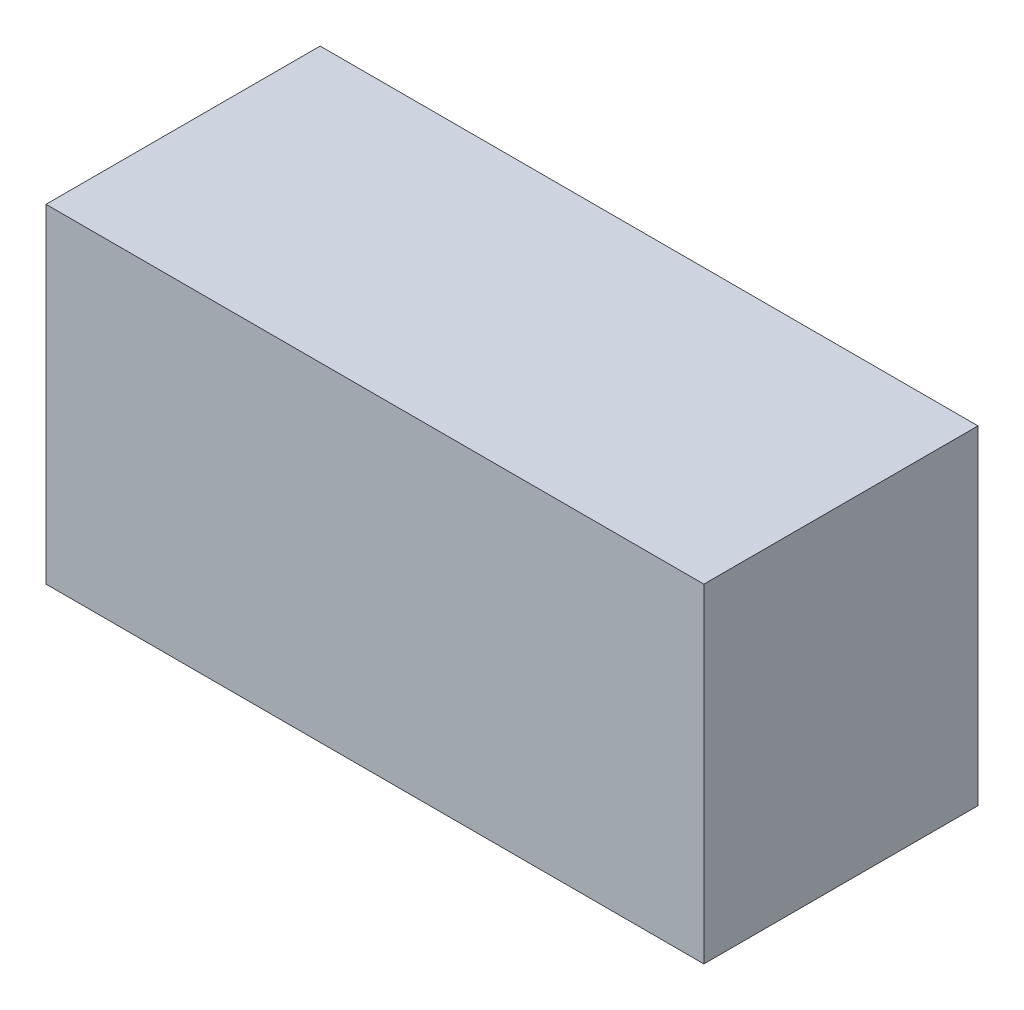
from build123d import *

# Parameters (mm, degrees)
SKETCH1_W           = 125
SKETCH1_H           = 150
BOSS_EXTRUDE1_DEPTH = 300


with BuildPart() as part:
    # Sketch1 → Boss-Extrude1 (new body)
    with BuildSketch(Plane(origin=(0, 0, 0), x_dir=(0, 0, -1), z_dir=(1, 0, 0))):
        with Locations((62.5, 75)):
            Rectangle(SKETCH1_W, SKETCH1_H)
    extrude(amount=BOSS_EXTRUDE1_DEPTH)


solid = part.part
